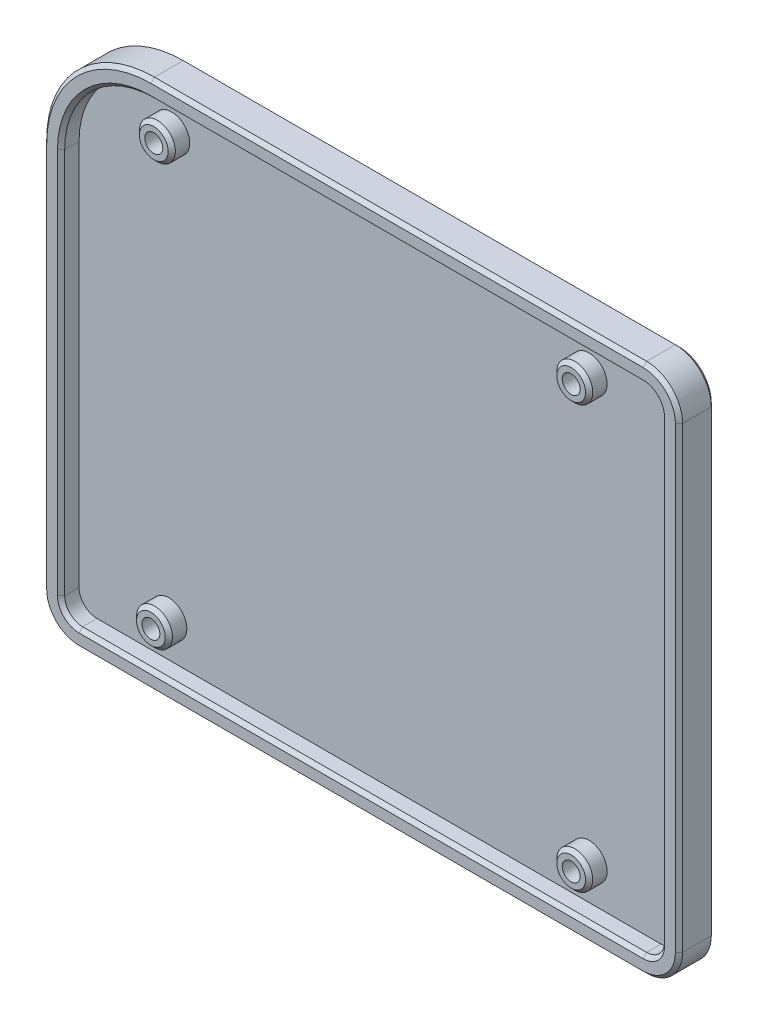
from build123d import *

# Parameters (mm, degrees)
SKETCH1_W                       = 177
SKETCH1_H                       = 147.5
BOSS_EXTRUDE1_DEPTH             = 10
FILLET2_R                       = 30
FILLET3_R                       = 10
SKETCH6_W                       = 177
SKETCH6_H                       = 10
CUT_EXTRUDE14_DEPTH             = 74.75
CUT_EXTRUDE14_DEPTH_BACK        = 74.75
SHELL1_T                        = -5
CHAMFER1_SIZE                   = 1
TAP_DRILL_FOR_M6X1_0_TAP1_D     = 5
TAP_DRILL_FOR_M6X1_0_TAP1_DEPTH = 18
TAP_DRILL_FOR_M6X1_0_TAP1_TIP   = 1.502151548
SKETCH9_R                       = 5
SKETCH9_R_2                     = 2.5
BOSS_EXTRUDE2_DEPTH             = 5
CHAMFER2_SIZE                   = 1


with BuildPart() as part:
    # Sketch1 → Boss-Extrude1 (new body, symmetric)
    with BuildSketch(Plane.XY):
        Rectangle(SKETCH1_W, SKETCH1_H)
    extrude(amount=BOSS_EXTRUDE1_DEPTH, both=True)

    # Fillet2
    fillet2_edges = [part.edges().sort_by_distance(p)[0] for p in [
        (-88.5, 73.75, 0),
    ]]
    fillet(fillet2_edges, radius=FILLET2_R)

    # Fillet3
    fillet3_edges = [part.edges().sort_by_distance(p)[0] for p in [
        (88.5, -73.75, 0),
        (-88.5, -73.75, 0),
        (88.5, 73.75, 0),
    ]]
    fillet(fillet3_edges, radius=FILLET3_R)

    # Sketch6 → Cut-Extrude14 (cut, two sides)
    with BuildSketch(Plane(origin=(0, 0, 0), x_dir=(1, 0, 0), z_dir=(0, 1, 0))) as cut_extrude14_sk:
        with Locations((0, -5)):
            Rectangle(SKETCH6_W, SKETCH6_H)
    extrude(amount=CUT_EXTRUDE14_DEPTH, mode=Mode.SUBTRACT)
    extrude(cut_extrude14_sk.sketch, amount=-CUT_EXTRUDE14_DEPTH_BACK, mode=Mode.SUBTRACT)

    # Shell1
    shell1_openings = [part.faces().sort_by_distance(p)[0] for p in [
        (1.982233047, -1.982233047, 0),
    ]]
    offset(amount=SHELL1_T, openings=shell1_openings, kind=Kind.INTERSECTION)

    # Chamfer1
    chamfer1_edges = [part.edges().sort_by_distance(p)[0] for p in [
        (-88.5, -10, -10),
        (-79.713203436, 64.963203436, -10),
        (0, -73.75, -10),
        (10, 73.75, -10),
        (88.5, 0, -10),
        (85.571067812, 70.821067812, -10),
        (85.571067812, -70.821067812, -10),
        (-85.571067812, -70.821067812, -10),
        (85.571067812, 70.821067812, 0),
        (-79.713203436, 64.963203436, 0),
        (-85.571067812, -70.821067812, 0),
        (85.571067812, -70.821067812, 0),
        (88.5, 0, 0),
        (10, 73.75, 0),
        (0, -73.75, 0),
        (-88.5, -10, 0),
        (-83.5, -10, 0),
        (0, -68.75, 0),
        (-76.17766953, 61.42766953, 0),
        (-82.035533906, -67.285533906, 0),
        (82.035533906, -67.285533906, 0),
        (83.5, 0, 0),
        (82.035533906, 67.285533906, 0),
        (10, 68.75, 0),
    ]]
    chamfer(chamfer1_edges, length=CHAMFER1_SIZE)

    # Tap Drill for M6x1.0 Tap1
    with Locations(Plane(origin=(-88.5, -73.75, -10), x_dir=(-1, 0, 0), z_dir=(0, 0, -1))):
        with Locations((-147, 132.5), (-30.807394368, 132.5), (-30, 15), (-147, 14.999919373)):
            Hole(TAP_DRILL_FOR_M6X1_0_TAP1_D / 2, depth=TAP_DRILL_FOR_M6X1_0_TAP1_DEPTH)
            with Locations((0, 0, -(TAP_DRILL_FOR_M6X1_0_TAP1_DEPTH + TAP_DRILL_FOR_M6X1_0_TAP1_TIP / 2))):  # 118° drill point
                Cone(0, TAP_DRILL_FOR_M6X1_0_TAP1_D / 2, TAP_DRILL_FOR_M6X1_0_TAP1_TIP, mode=Mode.SUBTRACT)

    # Sketch9 → Boss-Extrude2 (add)
    with BuildSketch(Plane.XY.offset(-5)):
        with Locations((-57.692605632, 58.75)):
            Circle(SKETCH9_R)
        with Locations((-57.692605632, 58.75)):
            Circle(SKETCH9_R_2, mode=Mode.SUBTRACT)
        with Locations((58.5, 58.75)):
            Circle(SKETCH9_R)
        with Locations((58.5, 58.75)):
            Circle(SKETCH9_R_2, mode=Mode.SUBTRACT)
        with Locations((58.5, -58.750080627)):
            Circle(SKETCH9_R)
        with Locations((58.5, -58.750080627)):
            Circle(SKETCH9_R_2, mode=Mode.SUBTRACT)
        with Locations((-58.5, -58.75)):
            Circle(SKETCH9_R)
        with Locations((-58.5, -58.75)):
            Circle(SKETCH9_R_2, mode=Mode.SUBTRACT)
    extrude(amount=BOSS_EXTRUDE2_DEPTH)

    # Chamfer2
    chamfer2_edges = [part.edges().sort_by_distance(p)[0] for p in [
        (-62.692605632, 58.75, 0),
        (53.5, 58.75, 0),
        (53.5, -58.750080627, 0),
        (-63.5, -58.75, 0),
    ]]
    chamfer(chamfer2_edges, length=CHAMFER2_SIZE)


solid = part.part
